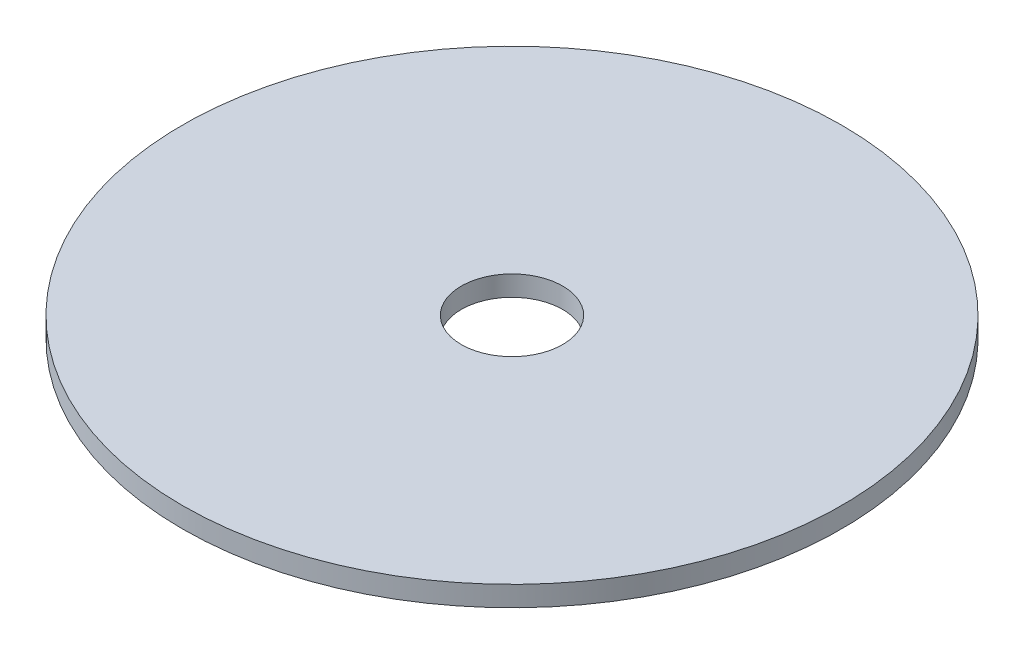
from build123d import *

# Parameters (mm, degrees)
SKETCH1_R           = 65
BOSS_EXTRUDE1_DEPTH = 4
SKETCH2_R           = 10
CUT_EXTRUDE1_DEPTH  = 10


with BuildPart() as part:
    # Sketch1 → Boss-Extrude1 (new body)
    with BuildSketch(Plane(origin=(0, 0, 0), x_dir=(1, 0, 0), z_dir=(0, 1, 0))):
        Circle(SKETCH1_R)
    extrude(amount=BOSS_EXTRUDE1_DEPTH)

    # Sketch2 → Cut-Extrude1 (cut)
    with BuildSketch(Plane(origin=(0, 4, 0), x_dir=(1, 0, 0), z_dir=(0, 1, 0))):
        Circle(SKETCH2_R)
    extrude(amount=-CUT_EXTRUDE1_DEPTH, mode=Mode.SUBTRACT)


solid = part.part
